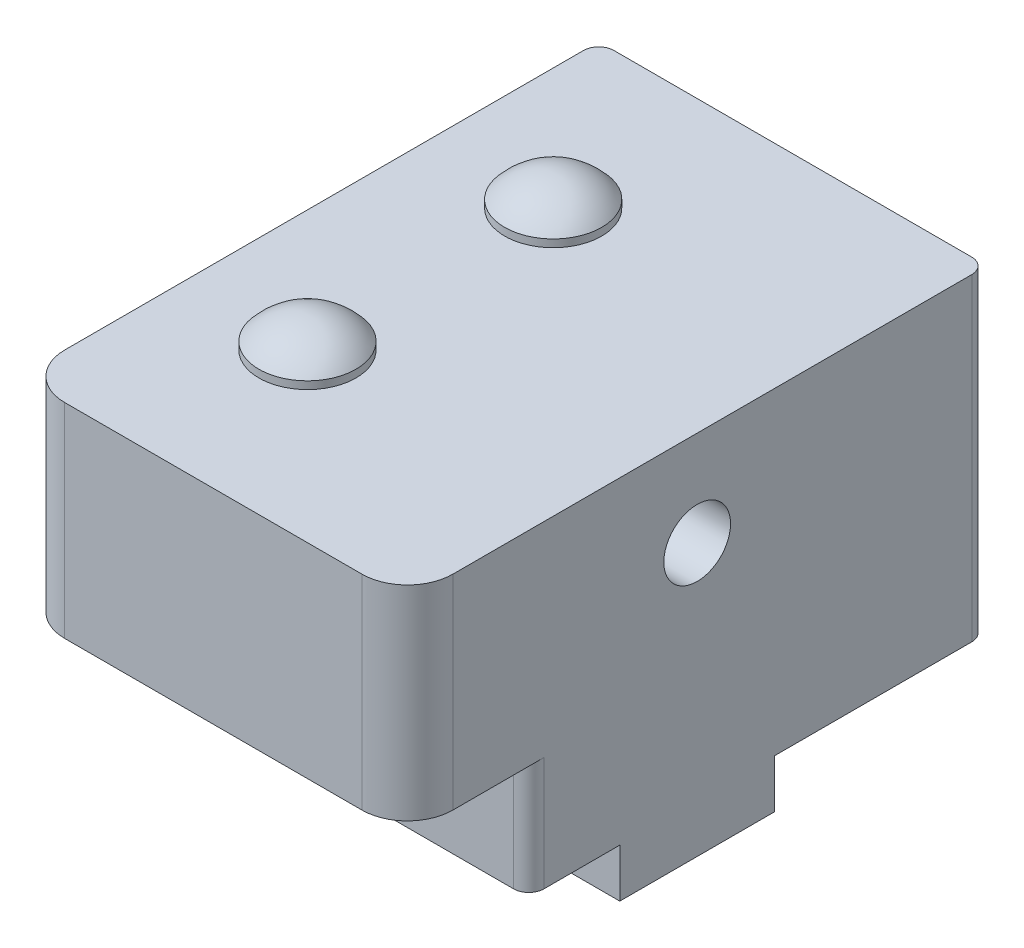
from build123d import *

# Parameters (mm, degrees)
SKETCH1_W           = 25.59
SKETCH1_H           = 38.2
BOSS_EXTRUDE1_DEPTH = 20.97
SKETCH2_W           = 25.59
SKETCH2_H           = 10.2
BOSS_EXTRUDE2_DEPTH = 3.2
SKETCH3_R           = 2.2
CUT_EXTRUDE1_DEPTH  = 25.59
SKETCH4_R           = 1.25
CUT_EXTRUDE2_DEPTH  = 5
FILLET1_R           = 1
FILLET2_R           = 1
FILLET3_R           = 3
SKETCH5_W           = 25.59
SKETCH5_H           = 8
CUT_EXTRUDE3_DEPTH  = 7.5
FILLET4_R           = 1
SKETCH6_R           = 3.2
BOSS_EXTRUDE4_DEPTH = 0.5
DOME1_FACE_RADIUS   = 3.2
DOME1_HEIGHT        = 1.5
DOME2_FACE_RADIUS   = 3.2
DOME2_HEIGHT        = 1.5


with BuildPart() as part:
    # Sketch1 → Boss-Extrude1 (new body)
    with BuildSketch(Plane(origin=(0, 0, 0), x_dir=(1, 0, 0), z_dir=(0, 1, 0))):
        with Locations((12.795, 19.1)):
            Rectangle(SKETCH1_W, SKETCH1_H)
    extrude(amount=BOSS_EXTRUDE1_DEPTH)

    # Sketch2 → Boss-Extrude2 (add)
    with BuildSketch(Plane.XZ):
        with Locations((12.795, -19.1)):
            Rectangle(SKETCH2_W, SKETCH2_H)
    extrude(amount=BOSS_EXTRUDE2_DEPTH)

    # Sketch3 → Cut-Extrude1 (cut)
    with BuildSketch(Plane(origin=(25.59, 0, 0), x_dir=(0, 0, -1), z_dir=(1, 0, 0))):
        with Locations((19.1, 14.7)):
            Circle(SKETCH3_R)
    extrude(amount=-CUT_EXTRUDE1_DEPTH, mode=Mode.SUBTRACT)

    # Sketch4 → Cut-Extrude2 (cut)
    with BuildSketch(Plane(origin=(0, 0, -38.2), x_dir=(-1, 0, 0), z_dir=(0, 0, -1))):
        with Locations((-22.59, 17.47)):
            Circle(SKETCH4_R)
        with Locations((-22.59, 4.5)):
            Circle(SKETCH4_R)
    cut_extrude2 = extrude(amount=-CUT_EXTRUDE2_DEPTH, mode=Mode.SUBTRACT)

    # Fillet1
    fillet1_edges = [part.edges().sort_by_distance(p)[0] for p in [
        (25.59, 10.485, -38.2),
    ]]
    fillet(fillet1_edges, radius=FILLET1_R)

    # Fillet2
    fillet2_edges = [part.edges().sort_by_distance(p)[0] for p in [
        (0, 10.485, -38.2),
    ]]
    fillet(fillet2_edges, radius=FILLET2_R)

    # Fillet3
    fillet3_edges = [part.edges().sort_by_distance(p)[0] for p in [
        (25.59, 10.485, 0),
        (0, 10.485, 0),
    ]]
    fillet(fillet3_edges, radius=FILLET3_R)

    # Sketch5 → Cut-Extrude3 (cut)
    with BuildSketch(Plane.XZ):
        with Locations((12.795, -4)):
            Rectangle(SKETCH5_W, SKETCH5_H)
    extrude(amount=-CUT_EXTRUDE3_DEPTH, mode=Mode.SUBTRACT)

    # Fillet4
    fillet4_edges = [part.edges().sort_by_distance(p)[0] for p in [
        (0, 3.75, -8),
        (25.59, 3.75, -8),
    ]]
    fillet(fillet4_edges, radius=FILLET4_R)

    # Sketch6 → Boss-Extrude4 (add)
    with BuildSketch(Plane(origin=(0, 20.97, 0), x_dir=(1, 0, 0), z_dir=(0, 1, 0))):
        with Locations((8, 27.2)):
            Circle(SKETCH6_R)
    boss_extrude4 = extrude(amount=BOSS_EXTRUDE4_DEPTH)

    # Mirror3: Boss-Extrude4 across plane
    add(boss_extrude4.mirror(Plane(origin=(0, 0, -19.1), x_dir=(1, 0, 0), z_dir=(0, 0, -1))))

    # Dome1: a dome of height H over a round flat face of radius A is a cap of a sphere of radius (A * A + H * H) / (2 * H)
    dome1_r = (DOME1_FACE_RADIUS * DOME1_FACE_RADIUS + DOME1_HEIGHT * DOME1_HEIGHT) / (2 * DOME1_HEIGHT)
    dome1_base = Plane((8, 21.47, -11), z_dir=(0, 1, 0))
    with Locations(dome1_base.offset(DOME1_HEIGHT - dome1_r)):
        dome1_ball = Sphere(dome1_r, mode=Mode.PRIVATE)
    add(split(dome1_ball, bisect_by=dome1_base, keep=Keep.TOP, mode=Mode.PRIVATE))

    # Dome2: a dome of height H over a round flat face of radius A is a cap of a sphere of radius (A * A + H * H) / (2 * H)
    dome2_r = (DOME2_FACE_RADIUS * DOME2_FACE_RADIUS + DOME2_HEIGHT * DOME2_HEIGHT) / (2 * DOME2_HEIGHT)
    dome2_base = Plane((8, 21.47, -27.2), z_dir=(0, 1, 0))
    with Locations(dome2_base.offset(DOME2_HEIGHT - dome2_r)):
        dome2_ball = Sphere(dome2_r, mode=Mode.PRIVATE)
    add(split(dome2_ball, bisect_by=dome2_base, keep=Keep.TOP, mode=Mode.PRIVATE))

    # Mirror4: Cut-Extrude2 across plane
    add(cut_extrude2.mirror(Plane(origin=(12.795, 0, 0), x_dir=(0, 0, 1), z_dir=(1, 0, 0))), mode=Mode.SUBTRACT)


solid = part.part
